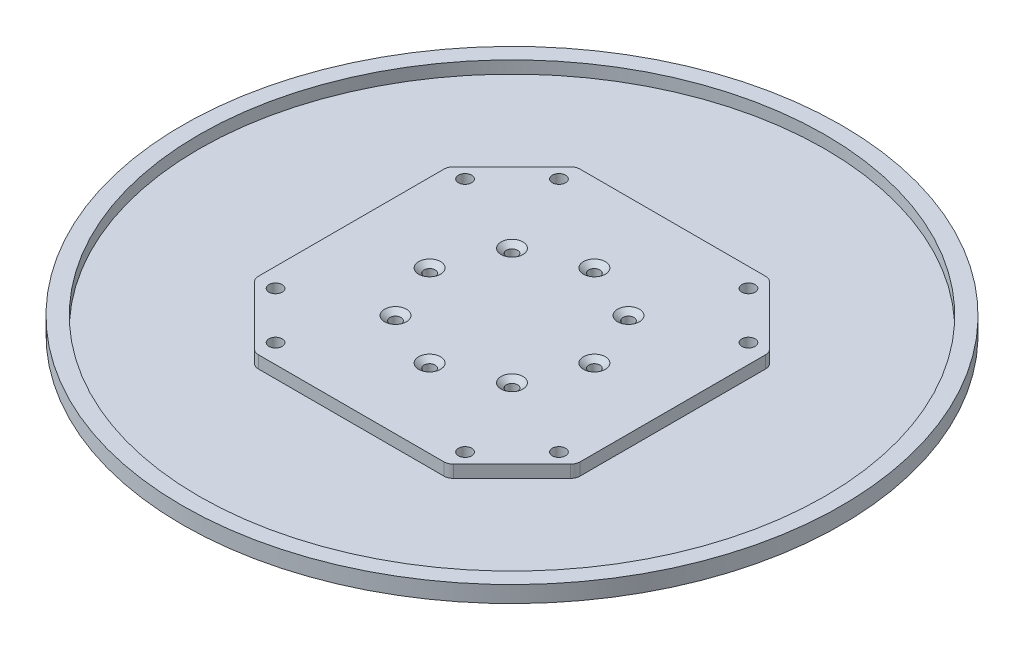
from build123d import *

# Parameters (mm, degrees)
SKETCH1_R                                         = 127
BOSS_EXTRUDE1_DEPTH                               = 6.35
F_7_0_201_DIAMETER_HOLE1_D                        = 5.1054
CIRPATTERN1_COUNT                                 = 4
CSK_FOR_8_FLAT_HEAD_MACHINE_SCREW_100_D           = 4.3053
CSK_FOR_8_FLAT_HEAD_MACHINE_SCREW_100_CSINK_D     = 8.4328
CSK_FOR_8_FLAT_HEAD_MACHINE_SCREW_100_CSINK_ANGLE = 100
CIRPATTERN2_COUNT                                 = 8
CUT_EXTRUDE1_DEPTH                                = 4.7625
FILLET1_R                                         = 3.683
CIRPATTERN3_COUNT                                 = 4
FILLET1_OF_CIRPATTERN3_R                          = 3.683


with BuildPart() as part:
    # Sketch1 → Boss-Extrude1 (new body)
    with BuildSketch(Plane(origin=(0, 0, 0), x_dir=(1, 0, 0), z_dir=(0, 1, 0))):
        with Locations(Location((0, 0, 0), (0, 0, 270))):  # turned: the seam where the file's is
            Circle(SKETCH1_R)
    extrude(amount=BOSS_EXTRUDE1_DEPTH)

    # 7 _0.201_ Diameter Hole1 (through all)
    with Locations(Plane(origin=(0, 6.35, 0), x_dir=(-1, 0, 0), z_dir=(0, 1, 0))):
        with Locations((36.5125, -54.61), (-36.5125, -54.61)):
            f_7_0_201_diameter_hole1 = Hole(F_7_0_201_DIAMETER_HOLE1_D / 2)

    # CirPattern1: 7 _0.201_ Diameter Hole1 ×4 about axis
    cirpattern1_axis = Axis((0, 0, 0), (0, 1, 0))
    for i in range(1, CIRPATTERN1_COUNT):
        add(f_7_0_201_diameter_hole1.rotate(cirpattern1_axis, i * 360 / CIRPATTERN1_COUNT), mode=Mode.SUBTRACT)

    # CSK for _8 Flat Head Machine Screw _100 (through all)
    with Locations(Plane(origin=(0, 6.35, 0), x_dir=(-1, 0, 0), z_dir=(0, 1, 0))):
        with Locations((0, 31.75)):
            csk_for_8_flat_head_machine_screw_100 = CounterSinkHole(CSK_FOR_8_FLAT_HEAD_MACHINE_SCREW_100_D / 2, CSK_FOR_8_FLAT_HEAD_MACHINE_SCREW_100_CSINK_D / 2, counter_sink_angle=CSK_FOR_8_FLAT_HEAD_MACHINE_SCREW_100_CSINK_ANGLE)

    # CirPattern2: CSK for _8 Flat Head Machine Screw _100 ×8 about axis
    cirpattern2_axis = Axis((0, 0, 0), (0, 1, 0))
    for i in range(1, CIRPATTERN2_COUNT):
        add(csk_for_8_flat_head_machine_screw_100.rotate(cirpattern2_axis, i * 360 / CIRPATTERN2_COUNT), mode=Mode.SUBTRACT)

    # Sketch6 → Cut-Extrude1 (cut)
    with BuildSketch(Plane(origin=(0, 6.35, 0), x_dir=(1, 0, 0), z_dir=(0, 1, 0))):
        with BuildLine():
            Line((-61.959197677, 0), (-61.959197677, 37.263493344))
            Line((-61.959197677, 37.263493344), (-37.263493344, 61.959197677))
            Line((-37.263493344, 61.959197677), (0, 61.959197677))
            Line((0, 61.959197677), (0, 120.65))
            ThreePointArc((0, 120.65), (-85.31243315, 85.31243315), (-120.65, 0))
            Line((-120.65, 0), (-61.959197677, 0))
        make_face()
    cut_extrude1 = extrude(amount=-CUT_EXTRUDE1_DEPTH, mode=Mode.SUBTRACT)

    # Fillet1
    fillet1_edges = [part.edges().sort_by_distance(p)[0] for p in [
        (-37.263493344, 3.96875, -61.959197677),
        (-61.959197677, 3.96875, -37.263493344),
    ]]
    fillet(fillet1_edges, radius=FILLET1_R)

    # CirPattern3: Cut-Extrude1 ×4 about axis
    cirpattern3_axis = Axis((0, 0, 0), (0, 1, 0))
    for i in range(1, CIRPATTERN3_COUNT):
        add(cut_extrude1.rotate(cirpattern3_axis, i * 360 / CIRPATTERN3_COUNT), mode=Mode.SUBTRACT)

    # Fillet1 of CirPattern3
    fillet1_of_cirpattern3_edges = [part.edges().sort_by_distance(p)[0] for p in [
        (-61.959197677, 3.96875, 37.263493344),
        (-37.263493344, 3.96875, 61.959197677),
        (37.263493344, 3.96875, 61.959197677),
        (61.959197677, 3.96875, 37.263493344),
        (61.959197677, 3.96875, -37.263493344),
        (37.263493344, 3.96875, -61.959197677),
    ]]
    fillet(fillet1_of_cirpattern3_edges, radius=FILLET1_OF_CIRPATTERN3_R)


solid = part.part
